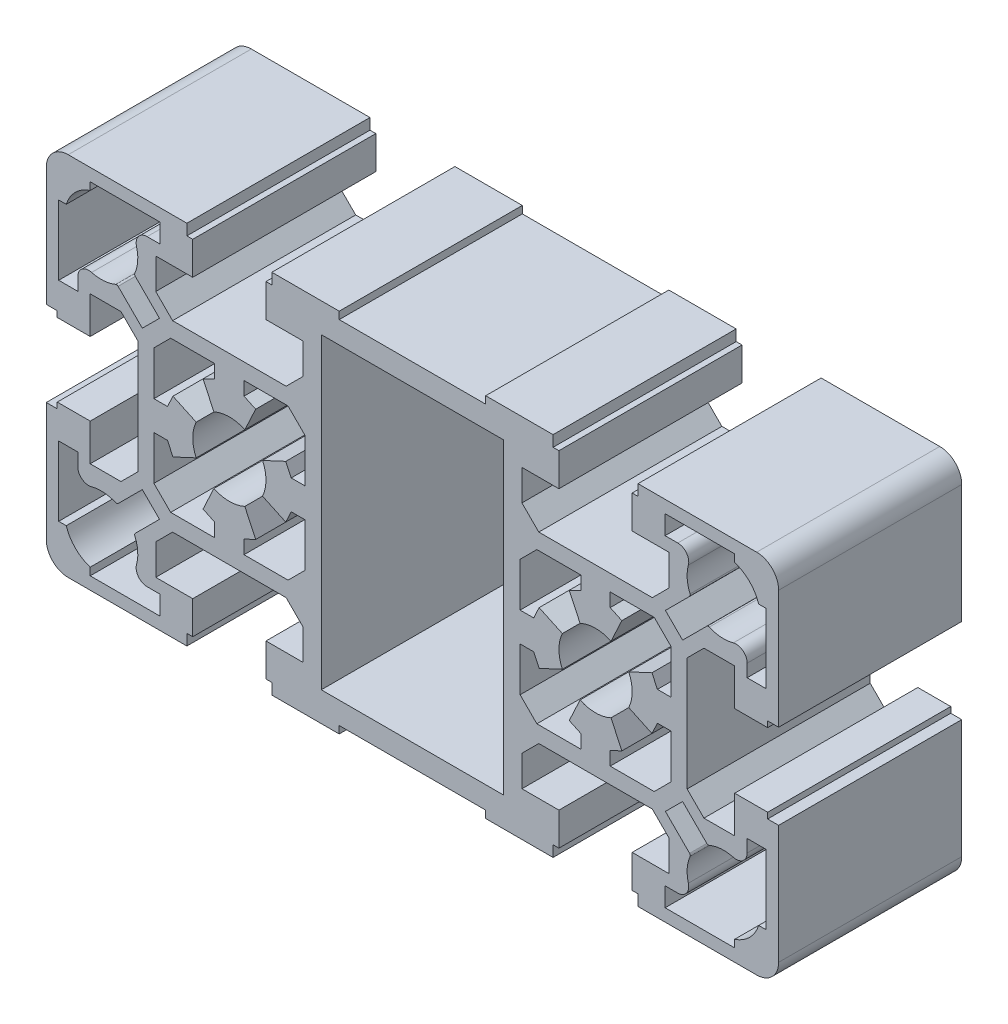
from build123d import *

# Parameters (mm, degrees)
SKETCH1_W           = 24.9
SKETCH1_H           = 42
BOSS_EXTRUDE1_DEPTH = 25


with BuildPart() as part:
    # Sketch1 → Boss-Extrude1 (new body)
    with BuildSketch(Plane(origin=(0, 0, 0), x_dir=(-1, 0, 0), z_dir=(0, 0, -1))):
        with BuildLine():
            Line((-30, -23.5), (-30, -19))
            Line((-30, -19), (-35.05, -19))
            Line((-35.05, -19), (-35.05, -14.8))
            Line((-35.05, -14.8), (-32.75, -12.5))
            Line((-32.75, -12.5), (-17.25, -12.5))
            Line((-17.25, -12.5), (-14.95, -14.8))
            Line((-14.95, -14.8), (-14.95, -19))
            Line((-14.95, -19), (-20, -19))
            Line((-20, -19), (-20, -23.5))
            Line((-20, -23.5), (-19.2, -23.5))
            Line((-19.2, -23.5), (-19.2, -25))
            Line((-19.2, -25), (-10, -25))
            Line((-10, -25), (-10, -24))
            Line((-10, -24), (10, -24))
            Line((10, -24), (10, -25))
            Line((10, -25), (19.2, -25))
            Line((19.2, -25), (19.2, -23.5))
            Line((19.2, -23.5), (20, -23.5))
            Line((20, -23.5), (20, -19))
            Line((20, -19), (14.95, -19))
            Line((14.95, -19), (14.95, -14.8))
            Line((14.95, -14.8), (17.25, -12.5))
            Line((17.25, -12.5), (32.75, -12.5))
            Line((32.75, -12.5), (35.05, -14.8))
            Line((35.05, -14.8), (35.05, -19))
            Line((35.05, -19), (30, -19))
            Line((30, -19), (30, -23.5))
            Line((30, -23.5), (30.8, -23.5))
            Line((30.8, -23.5), (30.8, -25))
            Line((30.8, -25), (47, -25))
            ThreePointArc((47, -25), (49.121320344, -24.121320344), (50, -22))
            Line((50, -22), (50, -5.8))
            Line((50, -5.8), (48.5, -5.8))
            Line((48.5, -5.8), (48.5, -5))
            Line((48.5, -5), (44, -5))
            Line((44, -5), (44, -10.05))
            Line((44, -10.05), (39.8, -10.05))
            Line((39.8, -10.05), (37.5, -7.75))
            Line((37.5, -7.75), (37.5, 7.75))
            Line((37.5, 7.75), (39.8, 10.05))
            Line((39.8, 10.05), (44, 10.05))
            Line((44, 10.05), (44, 5))
            Line((44, 5), (48.5, 5))
            Line((48.5, 5), (48.5, 5.8))
            Line((48.5, 5.8), (50, 5.8))
            Line((50, 5.8), (50, 22))
            ThreePointArc((50, 22), (49.121320344, 24.121320344), (47, 25))
            Line((47, 25), (30.8, 25))
            Line((30.8, 25), (30.8, 23.5))
            Line((30.8, 23.5), (30, 23.5))
            Line((30, 23.5), (30, 19))
            Line((30, 19), (35.05, 19))
            Line((35.05, 19), (35.05, 14.8))
            Line((35.05, 14.8), (32.75, 12.5))
            Line((32.75, 12.5), (17.25, 12.5))
            Line((17.25, 12.5), (14.95, 14.8))
            Line((14.95, 14.8), (14.95, 19))
            Line((14.95, 19), (20, 19))
            Line((20, 19), (20, 23.5))
            Line((20, 23.5), (19.2, 23.5))
            Line((19.2, 23.5), (19.2, 25))
            Line((19.2, 25), (10, 25))
            Line((10, 25), (10, 24))
            Line((10, 24), (-10, 24))
            Line((-10, 24), (-10, 25))
            Line((-10, 25), (-19.2, 25))
            Line((-19.2, 25), (-19.2, 23.5))
            Line((-19.2, 23.5), (-20, 23.5))
            Line((-20, 23.5), (-20, 19))
            Line((-20, 19), (-14.95, 19))
            Line((-14.95, 19), (-14.95, 14.8))
            Line((-14.95, 14.8), (-17.25, 12.5))
            Line((-17.25, 12.5), (-32.75, 12.5))
            Line((-32.75, 12.5), (-35.05, 14.8))
            Line((-35.05, 14.8), (-35.05, 19))
            Line((-35.05, 19), (-30, 19))
            Line((-30, 19), (-30, 23.5))
            Line((-30, 23.5), (-30.8, 23.5))
            Line((-30.8, 23.5), (-30.8, 25))
            Line((-30.8, 25), (-47, 25))
            ThreePointArc((-47, 25), (-49.121320344, 24.121320344), (-50, 22))
            Line((-50, 22), (-50, 5.8))
            Line((-50, 5.8), (-48.5, 5.8))
            Line((-48.5, 5.8), (-48.5, 5))
            Line((-48.5, 5), (-44, 5))
            Line((-44, 5), (-44, 10.05))
            Line((-44, 10.05), (-39.8, 10.05))
            Line((-39.8, 10.05), (-37.5, 7.75))
            Line((-37.5, 7.75), (-37.5, -7.75))
            Line((-37.5, -7.75), (-39.8, -10.05))
            Line((-39.8, -10.05), (-44, -10.05))
            Line((-44, -10.05), (-44, -5))
            Line((-44, -5), (-48.5, -5))
            Line((-48.5, -5), (-48.5, -5.8))
            Line((-48.5, -5.8), (-50, -5.8))
            Line((-50, -5.8), (-50, -22))
            ThreePointArc((-50, -22), (-49.121320344, -24.121320344), (-47, -25))
            Line((-47, -25), (-30.8, -25))
            Line((-30.8, -25), (-30.8, -23.5))
            Line((-30.8, -23.5), (-30, -23.5))
        make_face()
        with BuildLine():
            Line((37.844749681, -15.190586625), (34.538856429, -11.884693373))
            Line((34.538856429, -11.884693373), (36.884693373, -9.538856429))
            Line((36.884693373, -9.538856429), (40.190586625, -12.844749681))
            ThreePointArc((40.190586625, -12.844749681), (40.346274066, -12.927259816), (40.521432697, -12.908129855))
            ThreePointArc((40.521432697, -12.908129855), (42.144727644, -12.512637816), (43.807692308, -12.674034726))
            ThreePointArc((43.807692308, -12.674034726), (45.11146543, -12.417559866), (45.7, -11.226245143))
            Line((45.7, -11.226245143), (45.7, -9.5))
            Line((45.7, -9.5), (48.3, -9.5))
            Line((48.3, -9.5), (48.3, -19))
            Line((48.3, -19), (47.269696007, -19))
            ThreePointArc((47.269696007, -19), (46.035533906, -21.035533906), (44, -22.269696007))
            Line((44, -22.269696007), (44, -23.3))
            Line((44, -23.3), (34.5, -23.3))
            Line((34.5, -23.3), (34.5, -20.7))
            Line((34.5, -20.7), (36.226245143, -20.7))
            ThreePointArc((36.226245143, -20.7), (37.417559866, -20.11146543), (37.674034726, -18.807692308))
            ThreePointArc((37.674034726, -18.807692308), (37.512637816, -17.144727644), (37.908129855, -15.521432697))
            ThreePointArc((37.908129855, -15.521432697), (37.927259816, -15.346274066), (37.844749681, -15.190586625))
        make_face(mode=Mode.SUBTRACT)
        with BuildLine():
            Line((-40.190586625, -12.844749681), (-36.884693373, -9.538856429))
            Line((-36.884693373, -9.538856429), (-34.538856429, -11.884693373))
            Line((-34.538856429, -11.884693373), (-37.844749681, -15.190586625))
            ThreePointArc((-37.844749681, -15.190586625), (-37.927259816, -15.346274066), (-37.908129855, -15.521432697))
            ThreePointArc((-37.908129855, -15.521432697), (-37.512637816, -17.144727644), (-37.674034726, -18.807692308))
            ThreePointArc((-37.674034726, -18.807692308), (-37.417559866, -20.11146543), (-36.226245143, -20.7))
            Line((-36.226245143, -20.7), (-34.5, -20.7))
            Line((-34.5, -20.7), (-34.5, -23.3))
            Line((-34.5, -23.3), (-44, -23.3))
            Line((-44, -23.3), (-44, -22.269696007))
            ThreePointArc((-44, -22.269696007), (-46.035533906, -21.035533906), (-47.269696007, -19))
            Line((-47.269696007, -19), (-48.3, -19))
            Line((-48.3, -19), (-48.3, -9.5))
            Line((-48.3, -9.5), (-45.7, -9.5))
            Line((-45.7, -9.5), (-45.7, -11.226245143))
            ThreePointArc((-45.7, -11.226245143), (-45.11146543, -12.417559866), (-43.807692308, -12.674034726))
            ThreePointArc((-43.807692308, -12.674034726), (-42.144727644, -12.512637816), (-40.521432697, -12.908129855))
            ThreePointArc((-40.521432697, -12.908129855), (-40.346274066, -12.927259816), (-40.190586625, -12.844749681))
        make_face(mode=Mode.SUBTRACT)
        with BuildLine():
            Line((48.3, 19), (48.3, 9.5))
            Line((48.3, 9.5), (45.7, 9.5))
            Line((45.7, 9.5), (45.7, 11.226245143))
            ThreePointArc((45.7, 11.226245143), (45.11146543, 12.417559866), (43.807692308, 12.674034726))
            ThreePointArc((43.807692308, 12.674034726), (42.144727644, 12.512637816), (40.521432697, 12.908129855))
            ThreePointArc((40.521432697, 12.908129855), (40.346274066, 12.927259816), (40.190586625, 12.844749681))
            Line((40.190586625, 12.844749681), (36.884693373, 9.538856429))
            Line((36.884693373, 9.538856429), (34.538856429, 11.884693373))
            Line((34.538856429, 11.884693373), (37.844749681, 15.190586625))
            ThreePointArc((37.844749681, 15.190586625), (37.927259816, 15.346274066), (37.908129855, 15.521432697))
            ThreePointArc((37.908129855, 15.521432697), (37.512637816, 17.144727644), (37.674034726, 18.807692308))
            ThreePointArc((37.674034726, 18.807692308), (37.417559866, 20.11146543), (36.226245143, 20.7))
            Line((36.226245143, 20.7), (34.5, 20.7))
            Line((34.5, 20.7), (34.5, 23.3))
            Line((34.5, 23.3), (44, 23.3))
            Line((44, 23.3), (44, 22.269696007))
            ThreePointArc((44, 22.269696007), (46.035533906, 21.035533906), (47.269696007, 19))
            Line((47.269696007, 19), (48.3, 19))
        make_face(mode=Mode.SUBTRACT)
        with BuildLine():
            Line((-34.5, 23.3), (-34.5, 20.7))
            Line((-34.5, 20.7), (-36.226245143, 20.7))
            ThreePointArc((-36.226245143, 20.7), (-37.417559866, 20.11146543), (-37.674034726, 18.807692308))
            ThreePointArc((-37.674034726, 18.807692308), (-37.512637816, 17.144727644), (-37.908129855, 15.521432697))
            ThreePointArc((-37.908129855, 15.521432697), (-37.927259816, 15.346274066), (-37.844749681, 15.190586625))
            Line((-37.844749681, 15.190586625), (-34.538856429, 11.884693373))
            Line((-34.538856429, 11.884693373), (-36.884693373, 9.538856429))
            Line((-36.884693373, 9.538856429), (-40.190586625, 12.844749681))
            ThreePointArc((-40.190586625, 12.844749681), (-40.346274066, 12.927259816), (-40.521432697, 12.908129855))
            ThreePointArc((-40.521432697, 12.908129855), (-42.144727644, 12.512637816), (-43.807692308, 12.674034726))
            ThreePointArc((-43.807692308, 12.674034726), (-45.11146543, 12.417559866), (-45.7, 11.226245143))
            Line((-45.7, 11.226245143), (-45.7, 9.5))
            Line((-45.7, 9.5), (-48.3, 9.5))
            Line((-48.3, 9.5), (-48.3, 19))
            Line((-48.3, 19), (-47.269696007, 19))
            ThreePointArc((-47.269696007, 19), (-46.035533906, 21.035533906), (-44, 22.269696007))
            Line((-44, 22.269696007), (-44, 23.3))
            Line((-44, 23.3), (-34.5, 23.3))
        make_face(mode=Mode.SUBTRACT)
        with BuildLine():
            Line((-23, 10.3), (-16.987720036, 10.3))
            Line((-16.987720036, 10.3), (-14.7, 8.012279964))
            Line((-14.7, 8.012279964), (-14.7, 2))
            Line((-14.7, 2), (-16.553903005, 2))
            Line((-16.553903005, 2), (-17.29638381, 3.592255225))
            Line((-17.29638381, 3.592255225), (-20.468461065, 2.113091309))
            ThreePointArc((-20.468461065, 2.113091309), (-20, 0), (-20.468461065, -2.113091309))
            Line((-20.468461065, -2.113091309), (-17.29638381, -3.592255225))
            Line((-17.29638381, -3.592255225), (-16.553903005, -2))
            Line((-16.553903005, -2), (-14.7, -2))
            Line((-14.7, -2), (-14.7, -8.012279964))
            Line((-14.7, -8.012279964), (-16.987720036, -10.3))
            Line((-16.987720036, -10.3), (-23, -10.3))
            Line((-23, -10.3), (-23, -8.446096995))
            Line((-23, -8.446096995), (-21.407744775, -7.70361619))
            Line((-21.407744775, -7.70361619), (-22.886908691, -4.531538935))
            ThreePointArc((-22.886908691, -4.531538935), (-25, -5), (-27.113091309, -4.531538935))
            Line((-27.113091309, -4.531538935), (-28.592255225, -7.70361619))
            Line((-28.592255225, -7.70361619), (-27, -8.446096995))
            Line((-27, -8.446096995), (-27, -10.3))
            Line((-27, -10.3), (-33.012279964, -10.3))
            Line((-33.012279964, -10.3), (-35.3, -8.012279964))
            Line((-35.3, -8.012279964), (-35.3, -2))
            Line((-35.3, -2), (-33.446096995, -2))
            Line((-33.446096995, -2), (-32.70361619, -3.592255225))
            Line((-32.70361619, -3.592255225), (-29.531538935, -2.113091309))
            ThreePointArc((-29.531538935, -2.113091309), (-30, 0), (-29.531538935, 2.113091309))
            Line((-29.531538935, 2.113091309), (-32.70361619, 3.592255225))
            Line((-32.70361619, 3.592255225), (-33.446096995, 2))
            Line((-33.446096995, 2), (-35.3, 2))
            Line((-35.3, 2), (-35.3, 8.012279964))
            Line((-35.3, 8.012279964), (-33.012279964, 10.3))
            Line((-33.012279964, 10.3), (-27, 10.3))
            Line((-27, 10.3), (-27, 8.446096995))
            Line((-27, 8.446096995), (-28.592255225, 7.70361619))
            Line((-28.592255225, 7.70361619), (-27.113091309, 4.531538935))
            ThreePointArc((-27.113091309, 4.531538935), (-25, 5), (-22.886908691, 4.531538935))
            Line((-22.886908691, 4.531538935), (-21.407744775, 7.70361619))
            Line((-21.407744775, 7.70361619), (-23, 8.446096995))
            Line((-23, 8.446096995), (-23, 10.3))
        make_face(mode=Mode.SUBTRACT)
        with BuildLine():
            Line((35.3, -8.012279964), (33.012279964, -10.3))
            Line((33.012279964, -10.3), (27, -10.3))
            Line((27, -10.3), (27, -8.446096995))
            Line((27, -8.446096995), (28.592255225, -7.70361619))
            Line((28.592255225, -7.70361619), (27.113091309, -4.531538935))
            ThreePointArc((27.113091309, -4.531538935), (25, -5), (22.886908691, -4.531538935))
            Line((22.886908691, -4.531538935), (21.407744775, -7.70361619))
            Line((21.407744775, -7.70361619), (23, -8.446096995))
            Line((23, -8.446096995), (23, -10.3))
            Line((23, -10.3), (16.987720036, -10.3))
            Line((16.987720036, -10.3), (14.7, -8.012279964))
            Line((14.7, -8.012279964), (14.7, -2))
            Line((14.7, -2), (16.553903005, -2))
            Line((16.553903005, -2), (17.29638381, -3.592255225))
            Line((17.29638381, -3.592255225), (20.468461065, -2.113091309))
            ThreePointArc((20.468461065, -2.113091309), (20, 0), (20.468461065, 2.113091309))
            Line((20.468461065, 2.113091309), (17.29638381, 3.592255225))
            Line((17.29638381, 3.592255225), (16.553903005, 2))
            Line((16.553903005, 2), (14.7, 2))
            Line((14.7, 2), (14.7, 8.012279964))
            Line((14.7, 8.012279964), (16.987720036, 10.3))
            Line((16.987720036, 10.3), (23, 10.3))
            Line((23, 10.3), (23, 8.446096995))
            Line((23, 8.446096995), (21.407744775, 7.70361619))
            Line((21.407744775, 7.70361619), (22.886908691, 4.531538935))
            ThreePointArc((22.886908691, 4.531538935), (25, 5), (27.113091309, 4.531538935))
            Line((27.113091309, 4.531538935), (28.592255225, 7.70361619))
            Line((28.592255225, 7.70361619), (27, 8.446096995))
            Line((27, 8.446096995), (27, 10.3))
            Line((27, 10.3), (33.012279964, 10.3))
            Line((33.012279964, 10.3), (35.3, 8.012279964))
            Line((35.3, 8.012279964), (35.3, 2))
            Line((35.3, 2), (33.446096995, 2))
            Line((33.446096995, 2), (32.70361619, 3.592255225))
            Line((32.70361619, 3.592255225), (29.531538935, 2.113091309))
            ThreePointArc((29.531538935, 2.113091309), (30, 0), (29.531538935, -2.113091309))
            Line((29.531538935, -2.113091309), (32.70361619, -3.592255225))
            Line((32.70361619, -3.592255225), (33.446096995, -2))
            Line((33.446096995, -2), (35.3, -2))
            Line((35.3, -2), (35.3, -8.012279964))
        make_face(mode=Mode.SUBTRACT)
        Rectangle(SKETCH1_W, SKETCH1_H, mode=Mode.SUBTRACT)
    extrude(amount=-BOSS_EXTRUDE1_DEPTH)


solid = part.part
